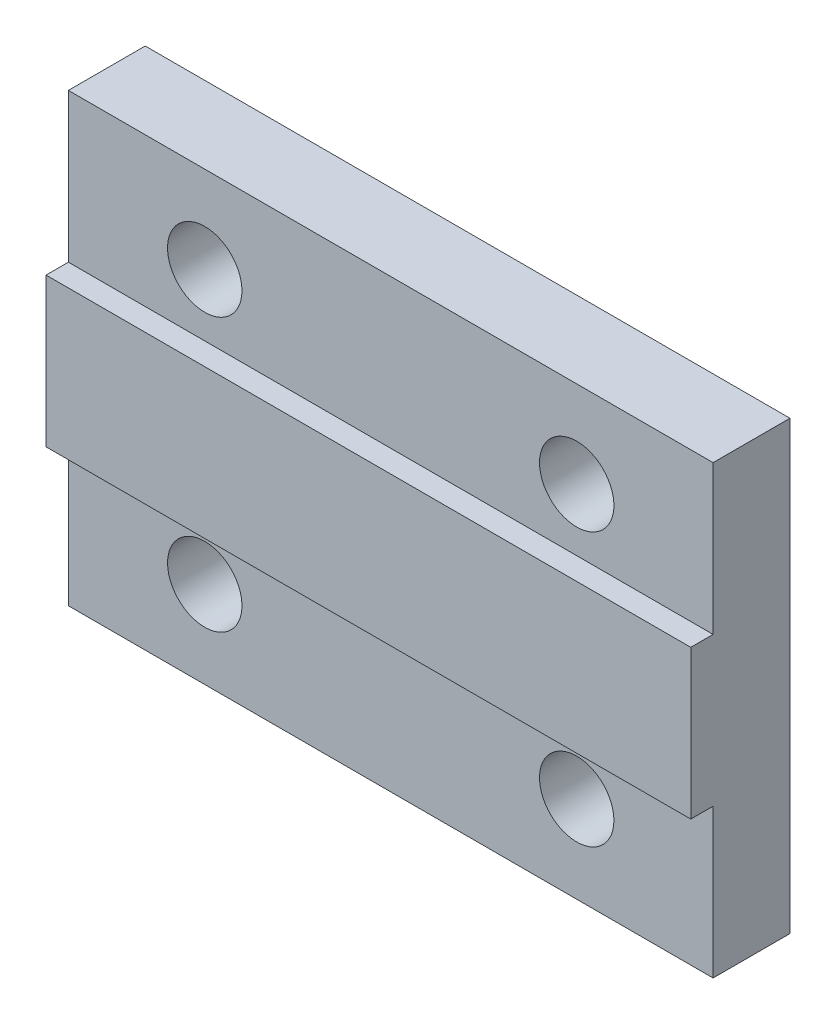
from build123d import *

# Parameters (mm, degrees)
SKETCH_1_W          = 26
SKETCH_1_H          = 18
EXTRUDE_1_DEPTH     = 4
SKETCH_2_W          = 0.9
SKETCH_2_H          = 6
CUT_EXTRUDE_1_DEPTH = 27
SKETCH_3_R          = 1.5
CUT_EXTRUDE_2_DEPTH = 4


with BuildPart() as part:
    # 草图1 → 凸台-拉伸1 (new body)
    with BuildSketch(Plane.XY):
        with Locations((13, 9)):
            Rectangle(SKETCH_1_W, SKETCH_1_H)
    extrude(amount=EXTRUDE_1_DEPTH)

    # 草图2 → 切除-拉伸1 (cut, through all)
    with BuildSketch(Plane(origin=(26, 0, 0), x_dir=(0, 0, -1), z_dir=(1, 0, 0))):
        with Locations((-3.55, 3)):
            Rectangle(SKETCH_2_W, SKETCH_2_H)
        with Locations((-3.55, 15)):
            Rectangle(SKETCH_2_W, SKETCH_2_H)
    extrude(amount=-CUT_EXTRUDE_1_DEPTH, mode=Mode.SUBTRACT)

    # 草图3 → 切除-拉伸2 (cut)
    with BuildSketch(Plane.XY.offset(3.1)):
        with Locations((5.5, 14.5)):
            Circle(SKETCH_3_R)
        with Locations((5.5, 3.5)):
            Circle(SKETCH_3_R)
        with Locations((20.5, 3.5)):
            Circle(SKETCH_3_R)
        with Locations((20.5, 14.5)):
            Circle(SKETCH_3_R)
    extrude(amount=-CUT_EXTRUDE_2_DEPTH, mode=Mode.SUBTRACT)


solid = part.part
